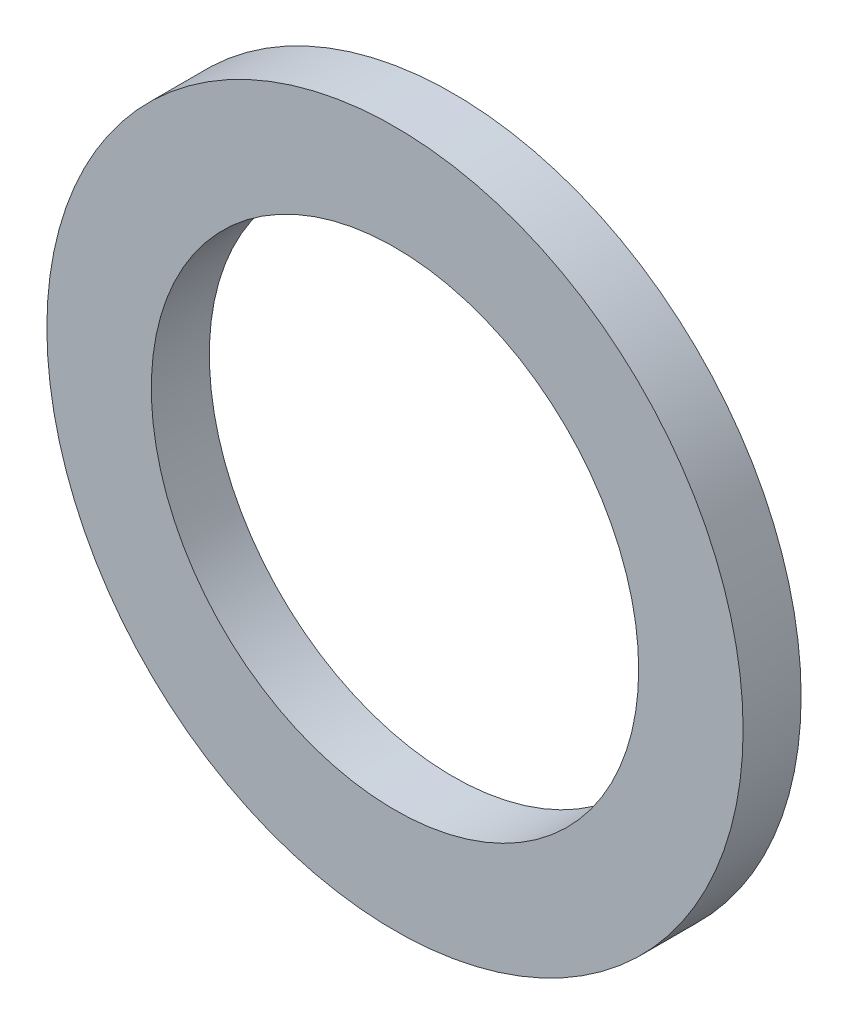
from build123d import *

# Parameters (mm, degrees)
ESQUISSE1_R      = 6
ESQUISSE1_R_2    = 4.2
EXTRUSION1_DEPTH = 0.5


with BuildPart() as part:
    # Esquisse1 → Extrusion1 (new body, symmetric)
    with BuildSketch(Plane.XY):
        Circle(ESQUISSE1_R)
        Circle(ESQUISSE1_R_2, mode=Mode.SUBTRACT)
    extrude(amount=EXTRUSION1_DEPTH, both=True)


solid = part.part
